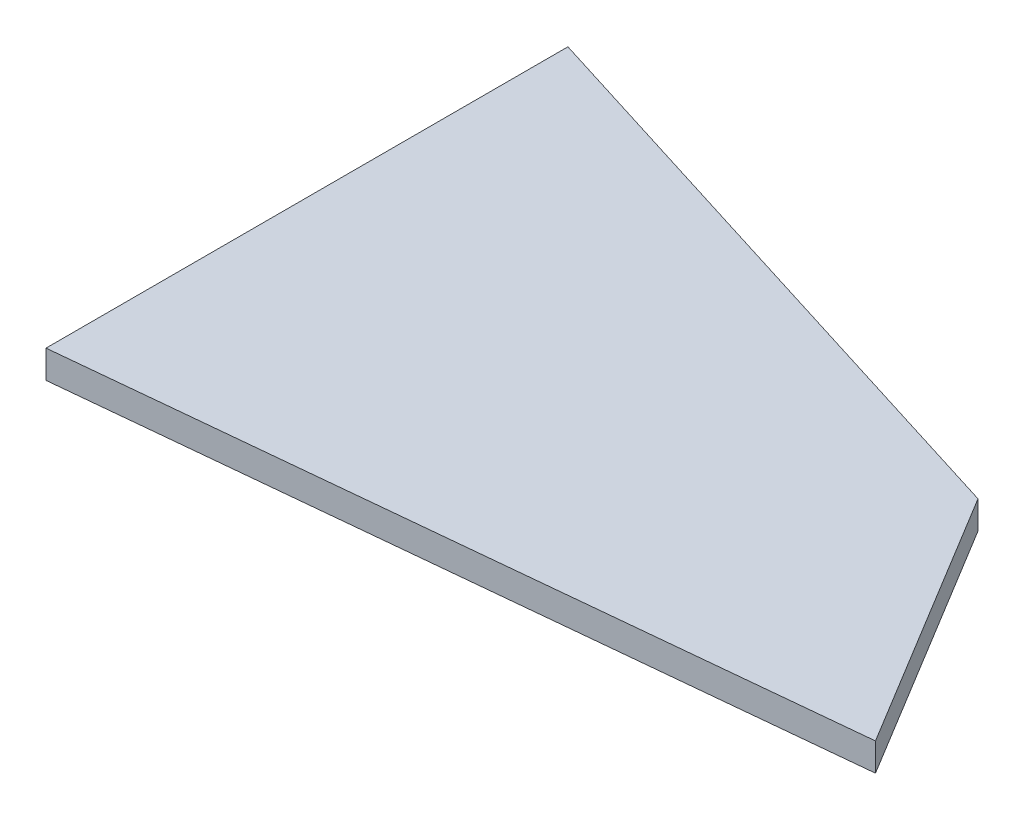
from build123d import *

# Parameters (mm, degrees)
BOSS_EXTRUDE1_DEPTH = 4.7625


with BuildPart() as part:
    # Sketch1 → Boss-Extrude1 (new body)
    with BuildSketch(Plane(origin=(0, 0, 0), x_dir=(1, 0, 0), z_dir=(0, 1, 0))):
        Polygon((0, 0), (0, 88.9), (101.6, 57.15), (128.5875, 12.7), align=None)
    extrude(amount=BOSS_EXTRUDE1_DEPTH)


solid = part.part
